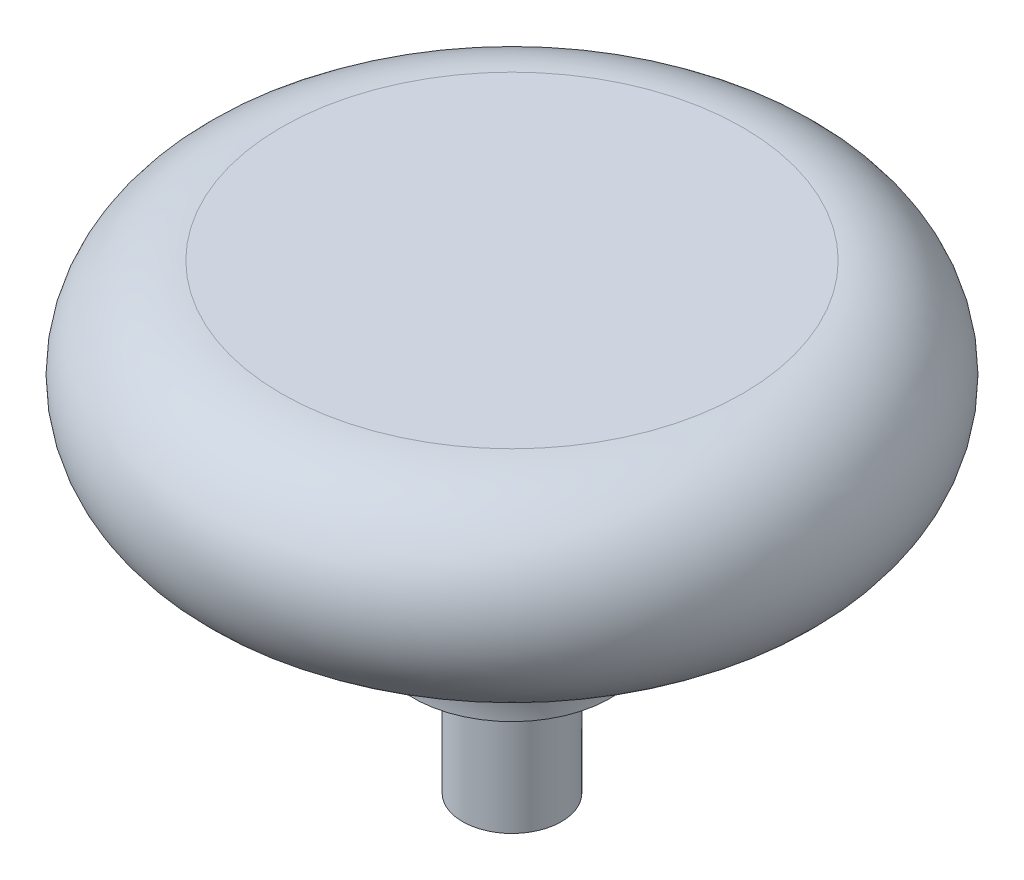
from build123d import *


with BuildPart() as part:
    # Sketch1 → Base-Revolve (revolve)
    with BuildSketch(Plane.XY):
        with BuildLine():
            Line((0, 0), (0, 22.225))
            Line((0, 22.225), (11.1125, 22.225))
            ThreePointArc((11.1125, 22.225), (15.875, 17.4625), (11.1125, 12.7))
            ThreePointArc((11.1125, 12.7), (6.622371939, 10.840128061), (4.7625, 6.35))
            Line((4.7625, 6.35), (2.38125, 6.35))
            Line((2.38125, 6.35), (2.38125, 0))
            Line((2.38125, 0), (0, 0))
        make_face()
    revolve(axis=Axis((0, 0, 0), (0, 1, 0)))


solid = part.part
